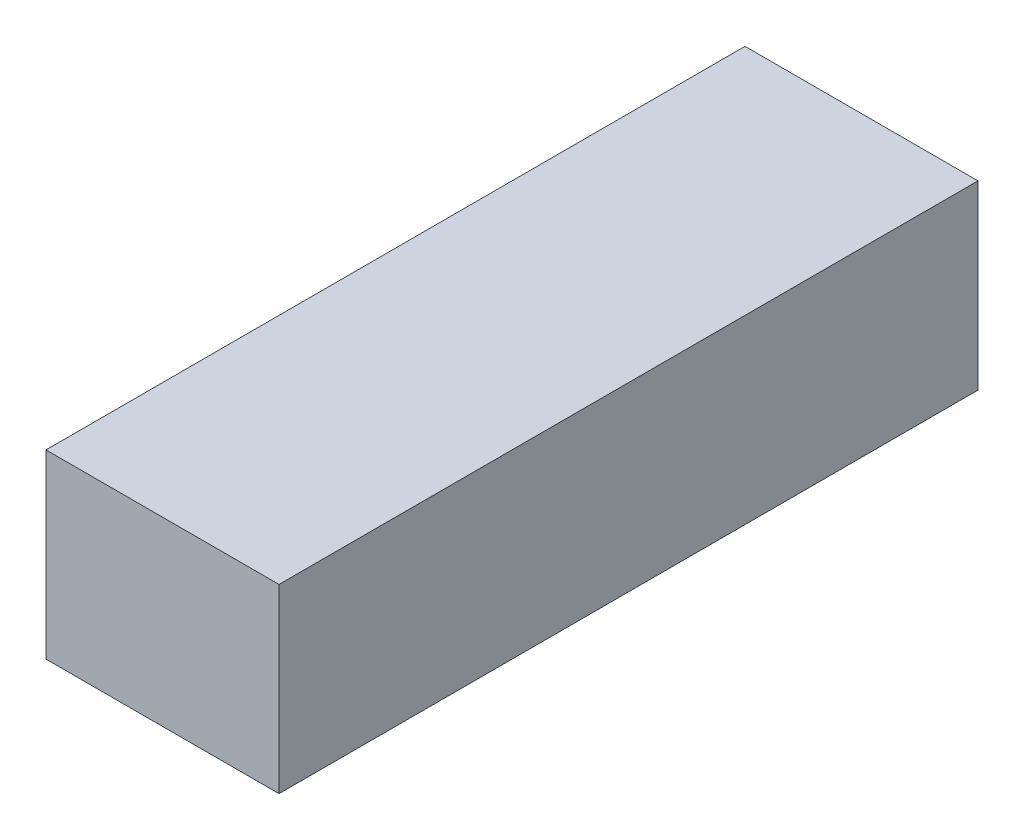
from build123d import *

# Parameters (mm, degrees)
SKETCH1_W           = 45
SKETCH1_H           = 135
BOSS_EXTRUDE1_DEPTH = 35


with BuildPart() as part:
    # Sketch1 → Boss-Extrude1 (new body)
    with BuildSketch(Plane(origin=(0, 0, 0), x_dir=(1, 0, 0), z_dir=(0, 1, 0))):
        Rectangle(SKETCH1_W, SKETCH1_H)
    extrude(amount=BOSS_EXTRUDE1_DEPTH)


solid = part.part
